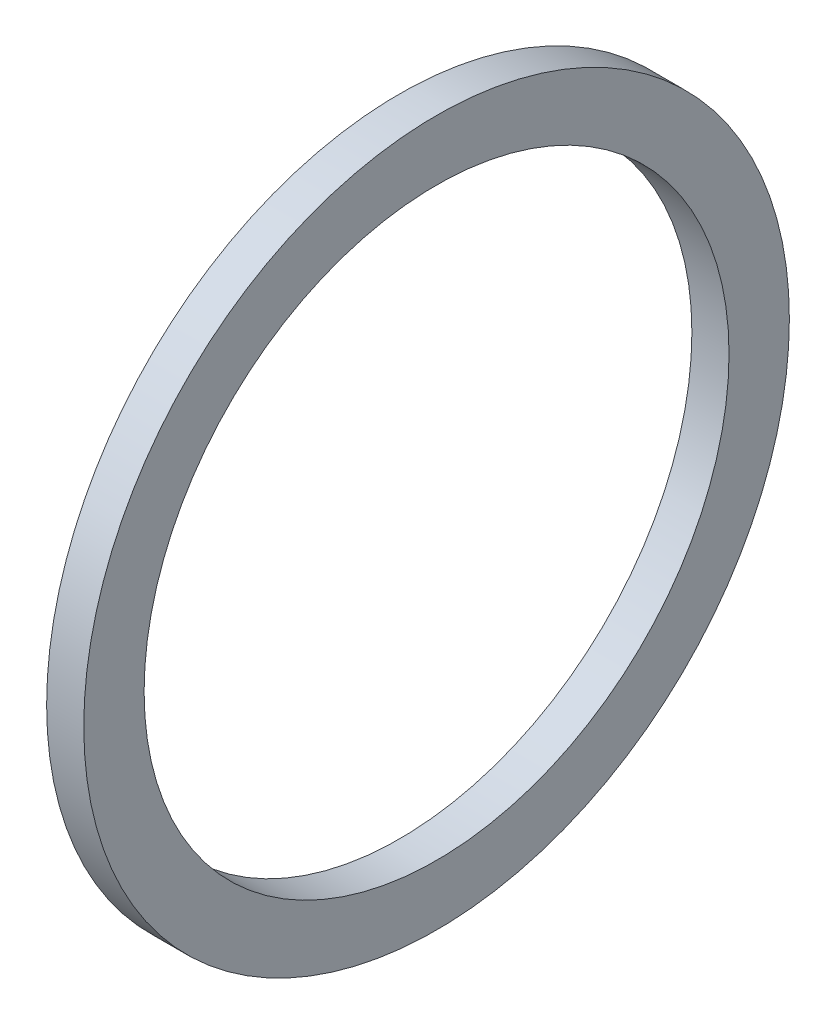
from build123d import *

# Parameters (mm, degrees)
SKETCH1_W = 2.032
SKETCH1_H = 3.302


with BuildPart() as part:
    # Sketch1 → Revolve1 (revolve)
    with BuildSketch(Plane.XY, mode=Mode.PRIVATE) as revolve1_sk:
        with Locations((1.016, -17.653)):
            Rectangle(SKETCH1_W, SKETCH1_H)
    revolve(revolve1_sk.sketch.rotate(Axis((-43.716580756, 0, 0), (1, 0, 0)), 270), axis=Axis((-43.716580756, 0, 0), (1, 0, 0)))  # turned: the seam where the file's is


solid = part.part
